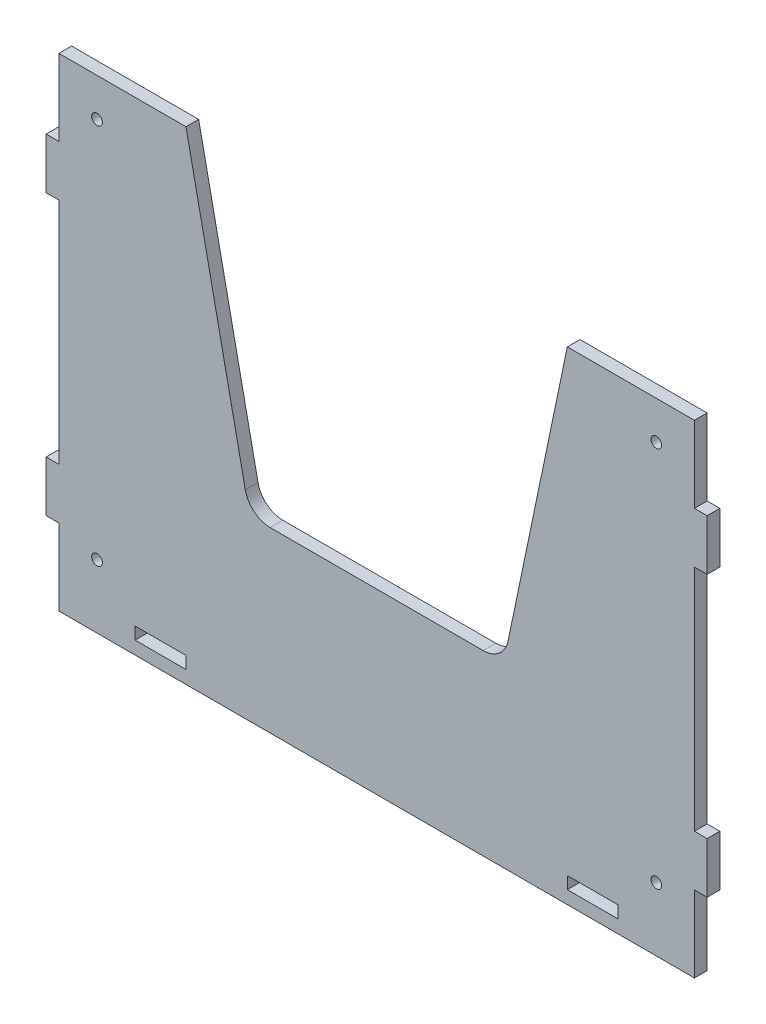
from build123d import *

# Parameters (mm, degrees)
SKETCH1_W           = 20
SKETCH1_H           = 4.8
BOSS_EXTRUDE1_DEPTH = 5
FILLET1_R           = 10
SKETCH2_R           = 2.1
CUT_EXTRUDE1_DEPTH  = 5


with BuildPart() as part:
    # Sketch1 → Boss-Extrude1 (new body)
    with BuildSketch(Plane.XY):
        Polygon((125.000000001, -10), (-124.999999999, -10), (-124.999999999, 20), (-129.999999999, 20), (-129.999999999, 40), (-124.999999999, 40), (-124.999999999, 130), (-129.999999999, 130), (-129.999999999, 150), (-124.999999999, 150), (-124.999999999, 180), (-74.999999999, 180), (-50, 60), (50, 60), (75.000000001, 180), (125.000000001, 180), (125.000000001, 150), (130.000000001, 150), (130.000000001, 130), (125.000000001, 130), (125.000000001, 40), (130.000000001, 40), (130.000000001, 20), (125.000000001, 20), align=None)
        with Locations((85.000000001, -2.5)):
            Rectangle(SKETCH1_W, SKETCH1_H, mode=Mode.SUBTRACT)
        with Locations((-84.999999999, -2.5)):
            Rectangle(SKETCH1_W, SKETCH1_H, mode=Mode.SUBTRACT)
    extrude(amount=BOSS_EXTRUDE1_DEPTH)

    # Fillet1
    fillet1_edges = [part.edges().sort_by_distance(p)[0] for p in [
        (-50, 60, 2.5),
        (50, 60, 2.5),
    ]]
    fillet(fillet1_edges, radius=FILLET1_R)

    # Sketch2 → Cut-Extrude1 (cut)
    with BuildSketch(Plane.XY.offset(5)):
        with Locations((-109.999999999, 15)):
            Circle(SKETCH2_R)
        with Locations((110.000000001, 15)):
            Circle(SKETCH2_R)
        with Locations((110.000000001, 165)):
            Circle(SKETCH2_R)
        with Locations((-109.999999999, 165)):
            Circle(SKETCH2_R)
    extrude(amount=-CUT_EXTRUDE1_DEPTH, mode=Mode.SUBTRACT)


solid = part.part
